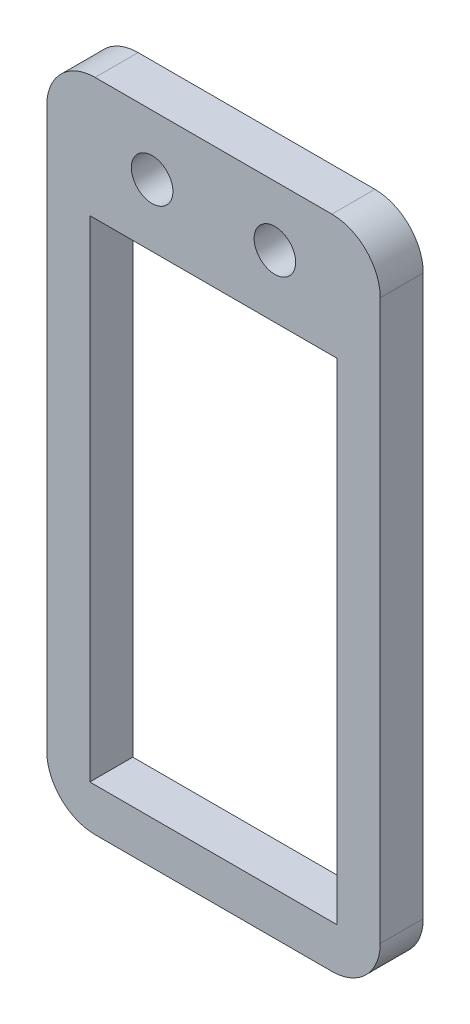
from build123d import *

# Parameters (mm, degrees)
SKETCH3_W           = 34.5
SKETCH3_H           = 67.853
SKETCH3_R           = 2.15
SKETCH3_W_2         = 25.6
SKETCH3_H_2         = 50.75
BOSS_EXTRUDE1_DEPTH = 4.45
FILLET1_R           = 5


with BuildPart() as part:
    # Sketch3 → Boss-Extrude1 (new body)
    with BuildSketch(Plane.XY.offset(-25.278270569)):
        with Locations((12.7, -27.7265)):
            Rectangle(SKETCH3_W, SKETCH3_H)
        with Locations((6.35, 0)):
            Circle(SKETCH3_R, mode=Mode.SUBTRACT)
        with Locations((19.05, 0)):
            Circle(SKETCH3_R, mode=Mode.SUBTRACT)
        with Locations((12.7, -31.828)):
            Rectangle(SKETCH3_W_2, SKETCH3_H_2, mode=Mode.SUBTRACT)
    extrude(amount=BOSS_EXTRUDE1_DEPTH)

    # Fillet1
    fillet1_edges = [part.edges().sort_by_distance(p)[0] for p in [
        (29.95, -61.653, -23.053270569),
        (-4.55, -61.653, -23.053270569),
        (-4.55, 6.2, -23.053270569),
        (29.95, 6.2, -23.053270569),
    ]]
    fillet(fillet1_edges, radius=FILLET1_R)


solid = part.part
